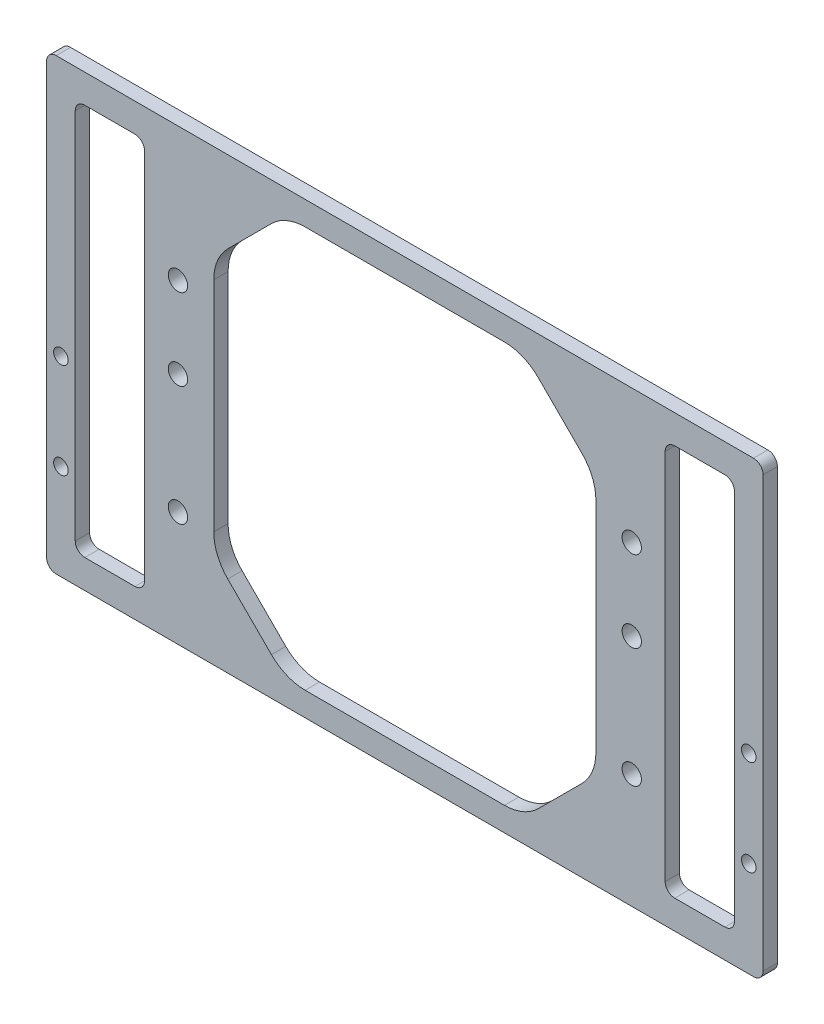
from build123d import *

# Parameters (mm, degrees)
SKETCH_1_W          = 150
SKETCH_1_H          = 94
SKETCH_1_R          = 2.025
SKETCH_1_W_2        = 80
SKETCH_1_H_2        = 84
EXTRUDE_1_DEPTH     = 3
CHAMFER_1_SIZE      = 15
FILLET_1_R          = 10
SKETCH_2_W          = 14.5
SKETCH_2_H          = 82
CUT_EXTRUDE_1_DEPTH = 10
FILLET_2_R          = 2
SKETCH_3_R          = 1.525
CUT_EXTRUDE_2_DEPTH = 10


with BuildPart() as part:
    # 草图1 → 凸台-拉伸1 (new body)
    with BuildSketch(Plane.XY):
        with Locations((0, -2)):
            Rectangle(SKETCH_1_W, SKETCH_1_H)
        with Locations((-47.5, 0)):
            Circle(SKETCH_1_R, mode=Mode.SUBTRACT)
        with Locations((-47.5, 17)):
            Circle(SKETCH_1_R, mode=Mode.SUBTRACT)
        with Locations((-47.5, -25)):
            Circle(SKETCH_1_R, mode=Mode.SUBTRACT)
        with Locations((47.5, -25)):
            Circle(SKETCH_1_R, mode=Mode.SUBTRACT)
        with Locations((47.5, 17)):
            Circle(SKETCH_1_R, mode=Mode.SUBTRACT)
        with Locations((47.5, 0)):
            Circle(SKETCH_1_R, mode=Mode.SUBTRACT)
        with Locations((0, -2)):
            Rectangle(SKETCH_1_W_2, SKETCH_1_H_2, mode=Mode.SUBTRACT)
    extrude(amount=EXTRUDE_1_DEPTH)

    # 倒角1
    chamfer_1_edges = [part.edges().sort_by_distance(p)[0] for p in [
        (40, -44, 1.5),
        (40, 40, 1.5),
        (-40, 40, 1.5),
        (-40, -44, 1.5),
    ]]
    chamfer(chamfer_1_edges, length=CHAMFER_1_SIZE)

    # 圆角1
    fillet_1_edges = [part.edges().sort_by_distance(p)[0] for p in [
        (-25, -44, 1.5),
        (25, -44, 1.5),
        (40, 25, 1.5),
        (40, -29, 1.5),
        (-25, 40, 1.5),
        (25, 40, 1.5),
        (-40, -29, 1.5),
        (-40, 25, 1.5),
    ]]
    fillet(fillet_1_edges, radius=FILLET_1_R)

    # 草图2 → 切除-拉伸1 (cut)
    with BuildSketch(Plane.XY.offset(3)):
        with Locations((-61.75, -2)):
            Rectangle(SKETCH_2_W, SKETCH_2_H)
        with Locations((61.75, -2)):
            Rectangle(SKETCH_2_W, SKETCH_2_H)
    extrude(amount=-CUT_EXTRUDE_1_DEPTH, mode=Mode.SUBTRACT)

    # 圆角2
    fillet_2_edges = [part.edges().sort_by_distance(p)[0] for p in [
        (-69, -43, 1.5),
        (-69, 39, 1.5),
        (-54.5, 39, 1.5),
        (-54.5, -43, 1.5),
        (69, 39, 1.5),
        (69, -43, 1.5),
        (54.5, -43, 1.5),
        (54.5, 39, 1.5),
        (-75, 45, 1.5),
        (75, 45, 1.5),
        (75, -49, 1.5),
        (-75, -49, 1.5),
    ]]
    fillet(fillet_2_edges, radius=FILLET_2_R)

    # 草图3 → 切除-拉伸2 (cut)
    with BuildSketch(Plane.XY.offset(3)):
        with Locations((72, -9)):
            Circle(SKETCH_3_R)
        with Locations((72, -29)):
            Circle(SKETCH_3_R)
        with Locations((-72, -29)):
            Circle(SKETCH_3_R)
        with Locations((-72, -9)):
            Circle(SKETCH_3_R)
    extrude(amount=-CUT_EXTRUDE_2_DEPTH, mode=Mode.SUBTRACT)


solid = part.part
